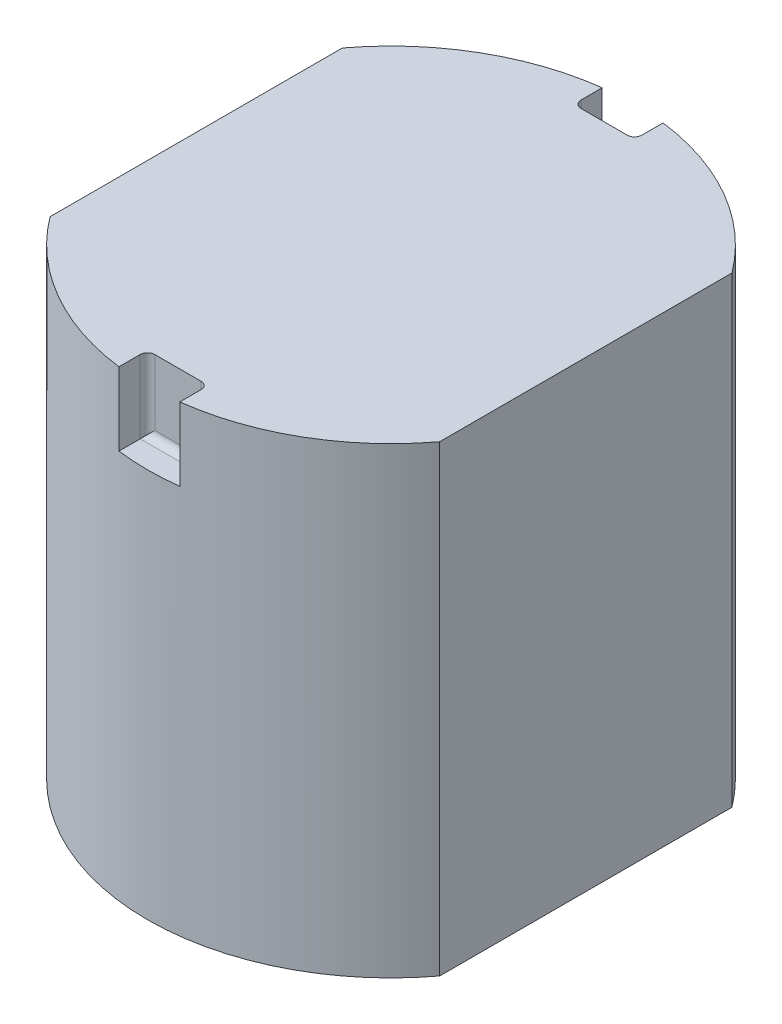
from build123d import *

# Parameters (mm, degrees)
BOSS_EXTRUDE1_DEPTH = 19
SKETCH2_W           = 2.5
SKETCH2_H           = 2.5
CUT_EXTRUDE1_DEPTH  = 3
FILLET1_R           = 0.3


with BuildPart() as part:
    # Sketch1 → Boss-Extrude1 (new body)
    with BuildSketch(Plane(origin=(0, 0, 0), x_dir=(1, 0, 0), z_dir=(0, 1, 0))):
        with BuildLine():
            Line((8, -6), (8, 6))
            ThreePointArc((8, 6), (0, 10), (-8, 6))
            Line((-8, 6), (-8, -6))
            ThreePointArc((-8, -6), (0, -10), (8, -6))
        make_face()
    extrude(amount=BOSS_EXTRUDE1_DEPTH)

    # Sketch2 → Cut-Extrude1 (cut)
    with BuildSketch(Plane(origin=(0, 19, 0), x_dir=(1, 0, 0), z_dir=(0, 1, 0))):
        with Locations((0, -10)):
            Rectangle(SKETCH2_W, SKETCH2_H)
    cut_extrude1 = extrude(amount=-CUT_EXTRUDE1_DEPTH, mode=Mode.SUBTRACT)

    # Mirror1: Cut-Extrude1 across plane
    add(cut_extrude1.mirror(Plane.XY), mode=Mode.SUBTRACT)

    # Fillet1
    fillet1_edges = [part.edges().sort_by_distance(p)[0] for p in [
        (1.25, 17.5, 8.75),
        (0, 16, 8.75),
        (-1.25, 17.5, 8.75),
        (0, 16, -8.75),
        (-1.25, 17.5, -8.75),
        (1.25, 17.5, -8.75),
    ]]
    fillet(fillet1_edges, radius=FILLET1_R)


solid = part.part
